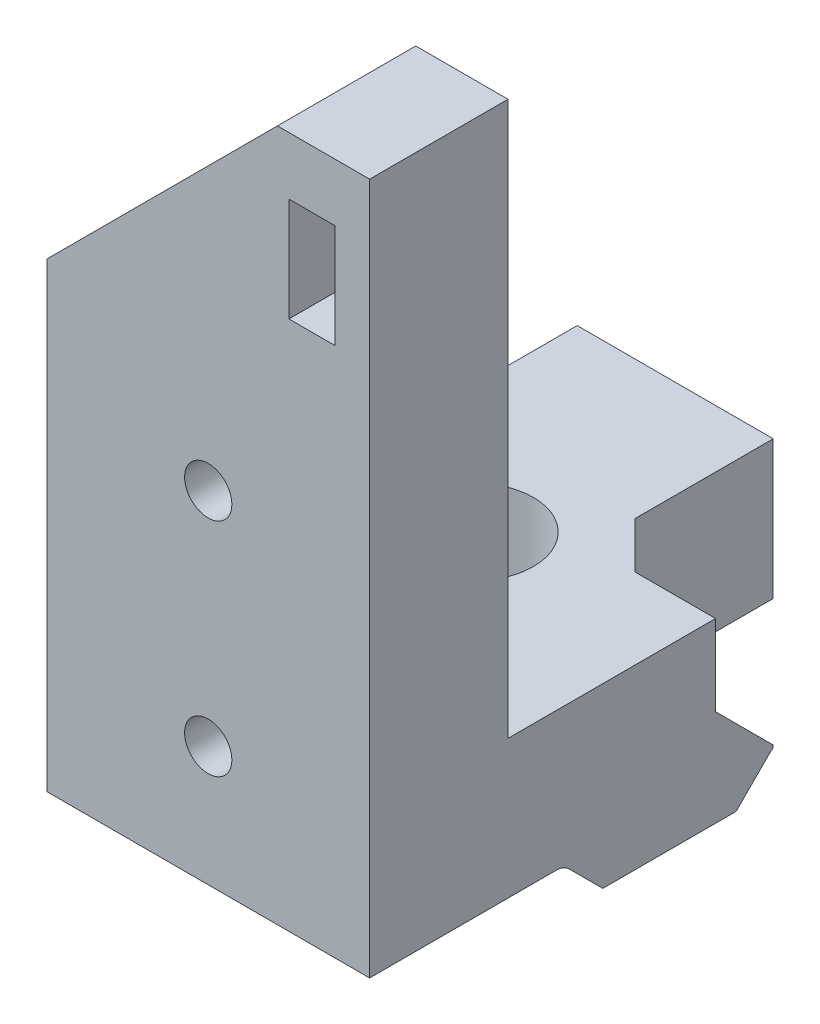
from build123d import *

# Parameters (mm, degrees)
SKETCH1_W                = 20
SKETCH1_H                = 6
BOSS_EXTRUDE1_DEPTH      = 14
CUT_EXTRUDE1_REACH       = 9.69
SKETCH2_R                = 2.6
SKETCH3_W                = 14
SKETCH3_H                = 20
BOSS_EXTRUDE2_DEPTH      = 3
BOSS_EXTRUDE2_DEPTH_BACK = 3
SKETCH4_R                = 1.025
CUT_EXTRUDE4_DEPTH       = 6
SKETCH5_W                = 5.5
SKETCH5_H                = 8
CUT_EXTRUDE5_DEPTH       = 6
CHAMFER1_SIZE            = 2
CHAMFER2_SIZE            = 2.5
SKETCH6_W                = 5.5
SKETCH6_H                = 0.407228715
CUT_EXTRUDE6_DEPTH       = 2.69
SKETCH7_W                = 2
SKETCH7_H                = 4.5
BOSS_EXTRUDE3_DEPTH      = 6


with BuildPart() as part:
    # Sketch1 → Boss-Extrude1 (new body)
    with BuildSketch(Plane(origin=(32.364284334, 0, 0), x_dir=(0, 0, -1), z_dir=(1, 0, 0))):
        with Locations((-7.875866483, 38.765059464)):
            Rectangle(SKETCH1_W, SKETCH1_H)
        with BuildLine():
            Line((-12.22448084, 35.533673821), (-10.765866483, 34.075059464))
            Line((-10.765866483, 34.075059464), (-4.985866483, 34.075059464))
            Line((-4.985866483, 34.075059464), (-3.527252126, 35.533673821))
            ThreePointArc((-3.527252126, 35.533673821), (-3.27095768, 35.704924294), (-2.968637768, 35.765059464))
            Line((-2.968637768, 35.765059464), (-12.783095197, 35.765059464))
            ThreePointArc((-12.783095197, 35.765059464), (-12.480775285, 35.704924294), (-12.22448084, 35.533673821))
        make_face()
    extrude(amount=BOSS_EXTRUDE1_DEPTH)

    # Sketch2 → Cut-Extrude1 (cut, up to next)
    with BuildSketch(Plane.XZ.offset(-34.075059464), mode=Mode.PRIVATE) as cut_extrude1_sk1:
        with Locations((37.864284334, 7.875866483)):
            Circle(SKETCH2_R)
    cut_extrude1_tool1 = extrude(cut_extrude1_sk1.sketch, amount=-CUT_EXTRUDE1_REACH, mode=Mode.PRIVATE) & part.part
    add(cut_extrude1_tool1.solids().sort_by_distance((37.864284, 34.075059, 7.875866))[0], mode=Mode.SUBTRACT)

    # Sketch3 → Boss-Extrude2 (add, two sides)
    with BuildSketch(Plane.XY.offset(17.875866483)) as boss_extrude2_sk:
        with Locations((39.364284334, 45.765059464)):
            Rectangle(SKETCH3_W, SKETCH3_H)
    extrude(amount=BOSS_EXTRUDE2_DEPTH)
    extrude(boss_extrude2_sk.sketch, amount=-BOSS_EXTRUDE2_DEPTH_BACK)

    # Sketch4 → Cut-Extrude4 (cut)
    with BuildSketch(Plane.XY.offset(20.875866483)):
        with Locations((39.364284334, 50.565059464)):
            Circle(SKETCH4_R)
        with Locations((39.364284334, 40.965059464)):
            Circle(SKETCH4_R)
    extrude(amount=-CUT_EXTRUDE4_DEPTH, mode=Mode.SUBTRACT)

    # Sketch5 → Cut-Extrude5 (cut)
    with BuildSketch(Plane(origin=(0, 41.765059464, 0), x_dir=(1, 0, 0), z_dir=(0, 1, 0))):
        with Locations((43.614284334, -1.875866483)):
            Rectangle(SKETCH5_W, SKETCH5_H)
    extrude(amount=-CUT_EXTRUDE5_DEPTH, mode=Mode.SUBTRACT)

    # Chamfer1
    chamfer1_edges = [part.edges().sort_by_distance(p)[0] for p in [
        (40.864284334, 38.765059464, 5.875866483),
    ]]
    chamfer(chamfer1_edges, length=CHAMFER1_SIZE)

    # Chamfer2
    chamfer2_edges = [part.edges().sort_by_distance(p)[0] for p in [
        (44.614284334, 35.765059464, 5.875866483),
    ]]
    chamfer(chamfer2_edges, length=CHAMFER2_SIZE)

    # Sketch6 → Cut-Extrude6 (cut, through all)
    with BuildSketch(Plane(origin=(0, 35.765059464, 0), x_dir=(1, 0, 0), z_dir=(0, 1, 0))):
        with Locations((43.614284334, -3.172252126)):
            Rectangle(SKETCH6_W, SKETCH6_H)
    extrude(amount=-CUT_EXTRUDE6_DEPTH, mode=Mode.SUBTRACT)

    # Sketch7 → Boss-Extrude3 (add)
    with BuildSketch(Plane.XY.offset(20.875866483)):
        Polygon((46.364284334, 55.765059464), (46.364284334, 65.765059464), (42.364284334, 65.765059464), (32.364284334, 55.765059464), align=None)
        with Locations((43.864284334, 61.015059464)):
            Rectangle(SKETCH7_W, SKETCH7_H, mode=Mode.SUBTRACT)
    extrude(amount=-BOSS_EXTRUDE3_DEPTH)


solid = part.part
